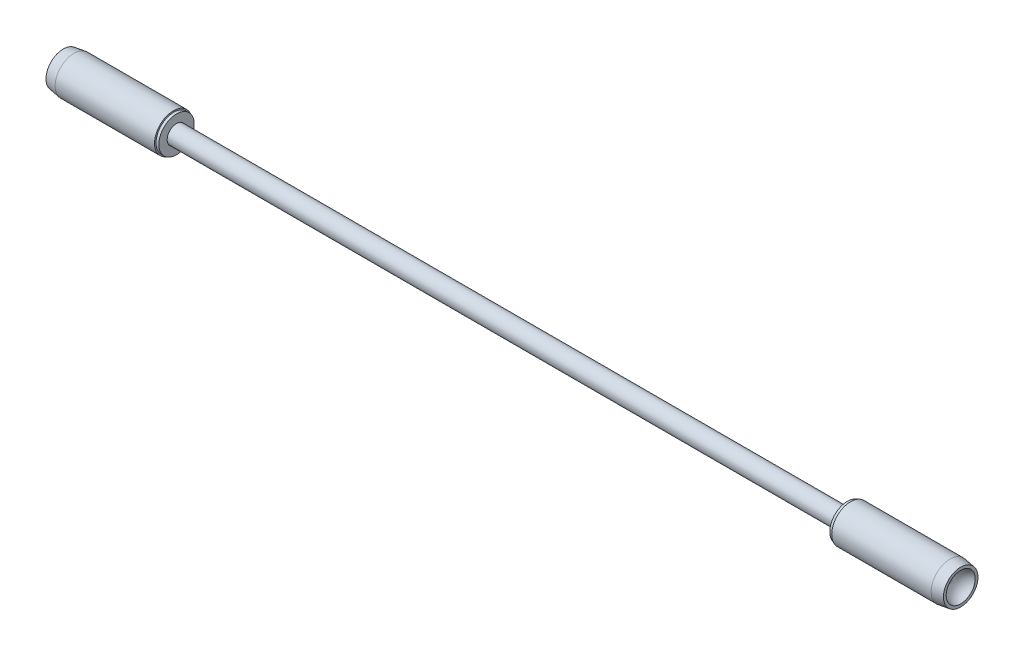
from build123d import *

# Parameters (mm, degrees)
SKETCH1_W   = 15
SKETCH1_H   = 5
SKETCH1_W_2 = 124.0375
SKETCH1_H_2 = 2.93


with BuildPart() as part:
    # Sketch1 → Revolve1 (revolve)
    with BuildSketch(Plane.XY):
        with BuildLine():
            ThreePointArc((-139.2375, 0.691917625), (-140.363006151, 3.151576113), (-142.6375, 4.615598553))
            Line((-142.6375, 4.615598553), (-142.6375, 5.5))
            Line((-142.6375, 5.5), (-139.2375, 6))
            Line((-139.2375, 6), (-107.6375, 6))
            Line((-107.6375, 6), (-107.6375, 5.1))
            Line((-107.6375, 5.1), (-139.2375, 5.1))
            Line((-139.2375, 5.1), (-139.2375, 0.691917625))
        make_face()
        with Locations((-131.6375, 2.5)):
            Rectangle(SKETCH1_W, SKETCH1_H)
        Polygon((-124.0375, 5), (-124.0375, 2.98), (-106.6375, 2.98), (-106.6375, 5.625), (-107.5375, 5.625), (-107.5375, 5), align=None)
        with Locations((-62.01875, 1.465)):
            Rectangle(SKETCH1_W_2, SKETCH1_H_2)
        with Locations((62.01875, 1.465)):
            Rectangle(SKETCH1_W_2, SKETCH1_H_2)
        Polygon((106.6375, 2.98), (106.6375, 5.625), (107.5375, 5.625), (107.5375, 5), (124.0375, 5), (124.0375, 2.98), align=None)
        with BuildLine():
            Line((139.2375, 0.691917625), (139.2375, 5.1))
            Line((139.2375, 5.1), (107.6375, 5.1))
            Line((107.6375, 5.1), (107.6375, 6))
            Line((107.6375, 6), (139.2375, 6))
            Line((139.2375, 6), (142.6375, 5.5))
            Line((142.6375, 5.5), (142.6375, 4.615598553))
            ThreePointArc((142.6375, 4.615598553), (140.363006151, 3.151576113), (139.2375, 0.691917625))
        make_face()
        with Locations((131.6375, 2.5)):
            Rectangle(SKETCH1_W, SKETCH1_H)
    revolve(axis=Axis((124.0375, 0, 0), (-1, 0, 0)))


solid = part.part
